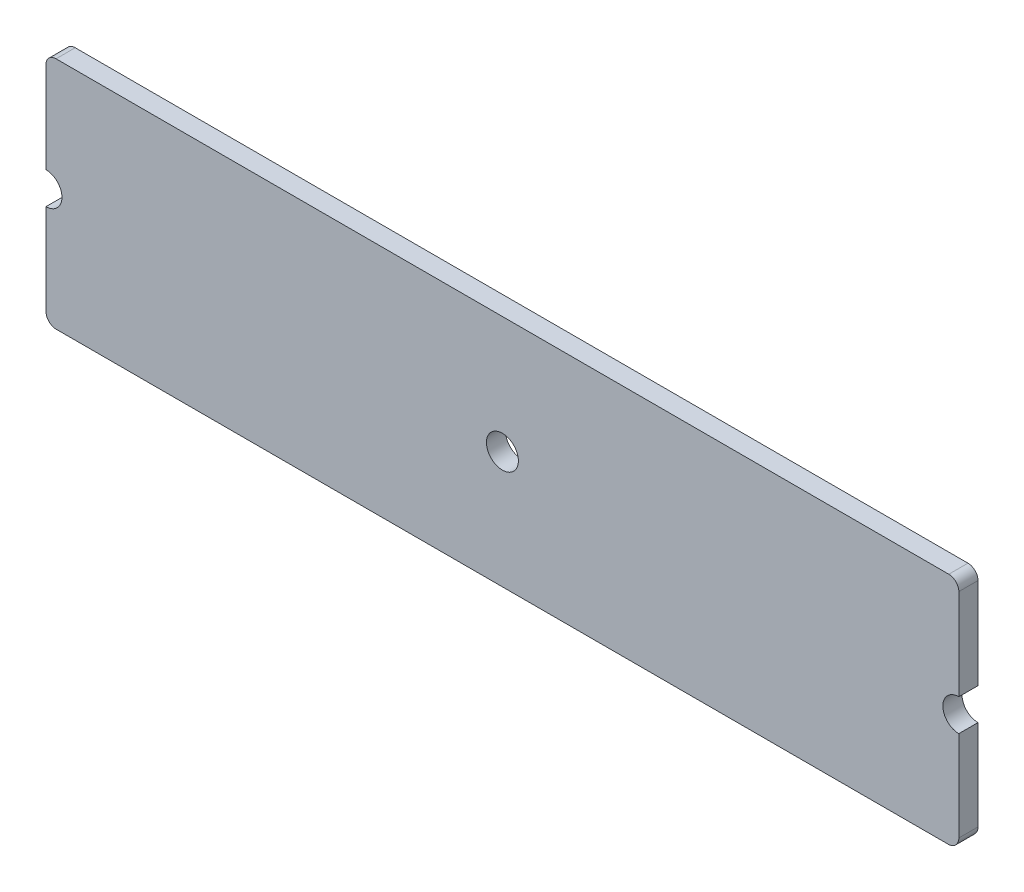
from build123d import *

# Parameters (mm, degrees)
SKETCH_1_R      = 1.74999904
EXTRUDE_1_DEPTH = 2.1


with BuildPart() as part:
    # Эскиз1 → Бобышка-Вытянуть1 (new body)
    with BuildSketch(Plane(origin=(0, 0, 0), x_dir=(-1, 0, 0), z_dir=(0, 0, -1))):
        with BuildLine():
            Line((-10, 52.299986006), (-10, 60.949899147))
            Line((-10, 60.949899147), (-10, 62.250001907))
            ThreePointArc((-10, 62.250001907), (-11.75, 64.000001907), (-10, 65.750001907))
            Line((-10, 65.750001907), (-10, 67.050104668))
            Line((-10, 67.050104668), (-10, 75.724998474))
            ThreePointArc((-10, 75.724998474), (-10.321999748, 76.50299855), (-11.100000381, 76.824996948))
            Line((-11.100000381, 76.824996948), (-108.900001526, 76.824996948))
            ThreePointArc((-108.900001526, 76.824996948), (-109.678001404, 76.502998352), (-110, 75.724998474))
            Line((-110, 75.724998474), (-110, 67.049927724))
            Line((-110, 67.049927724), (-110, 65.750001907))
            ThreePointArc((-110, 65.750001907), (-108.25, 64.000001907), (-110, 62.250001907))
            Line((-110, 62.250001907), (-110, 60.950076091))
            Line((-110, 60.950076091), (-110, 52.349998474))
            ThreePointArc((-110, 52.349998474), (-109.655996881, 51.518999658), (-108.824996948, 51.174999237))
            Line((-108.824996948, 51.174999237), (-11.124986768, 51.174999237))
            ThreePointArc((-11.124986768, 51.174999237), (-10.329500996, 51.504500233), (-10, 52.299986006))
        make_face()
        with Locations((-59.99999938, 63.999999)):
            Circle(SKETCH_1_R, mode=Mode.SUBTRACT)
    extrude(amount=-EXTRUDE_1_DEPTH)


solid = part.part
